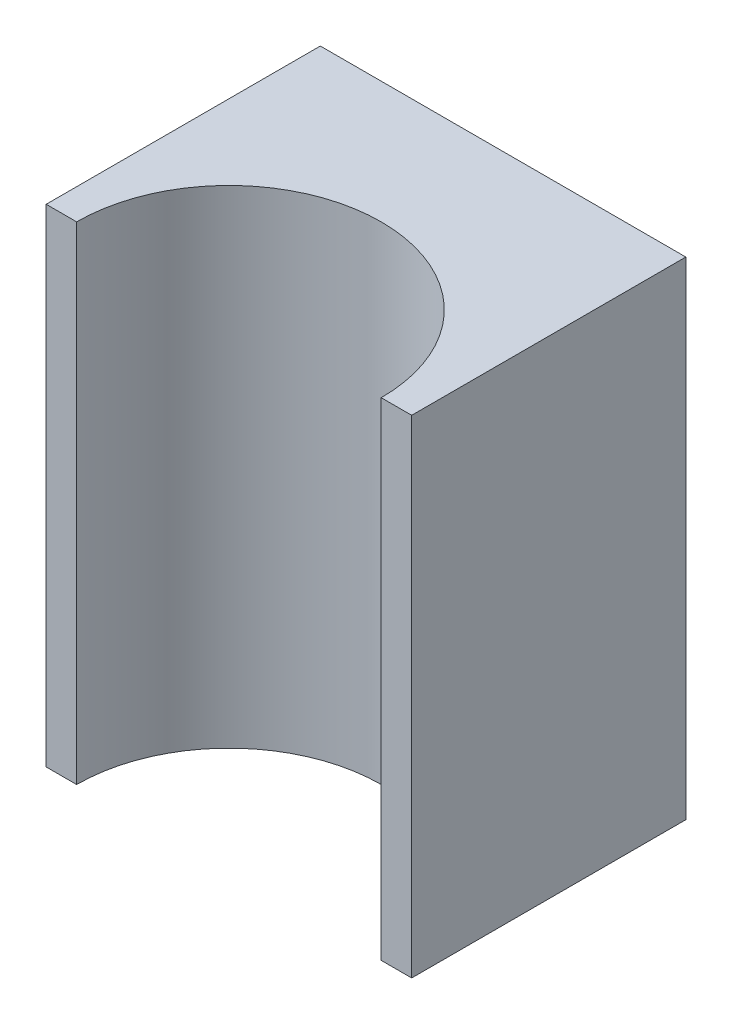
from build123d import *

# Parameters (mm, degrees)
BOSS_EXTRU_1_DEPTH = 0.8


with BuildPart() as part:
    # Esquisse1 → Boss.-Extru.1 (new body)
    with BuildSketch(Plane(origin=(0, 0, 0), x_dir=(1, 0, 0), z_dir=(0, 1, 0))):
        with BuildLine():
            Line((0.25, -0.225), (0.3, -0.225))
            Line((0.3, -0.225), (0.3, 0.225))
            Line((0.3, 0.225), (-0.3, 0.225))
            Line((-0.3, 0.225), (-0.3, -0.225))
            Line((-0.3, -0.225), (-0.25, -0.225))
            ThreePointArc((-0.25, -0.225), (0, 0.025), (0.25, -0.225))
        make_face()
    extrude(amount=BOSS_EXTRU_1_DEPTH)


solid = part.part
